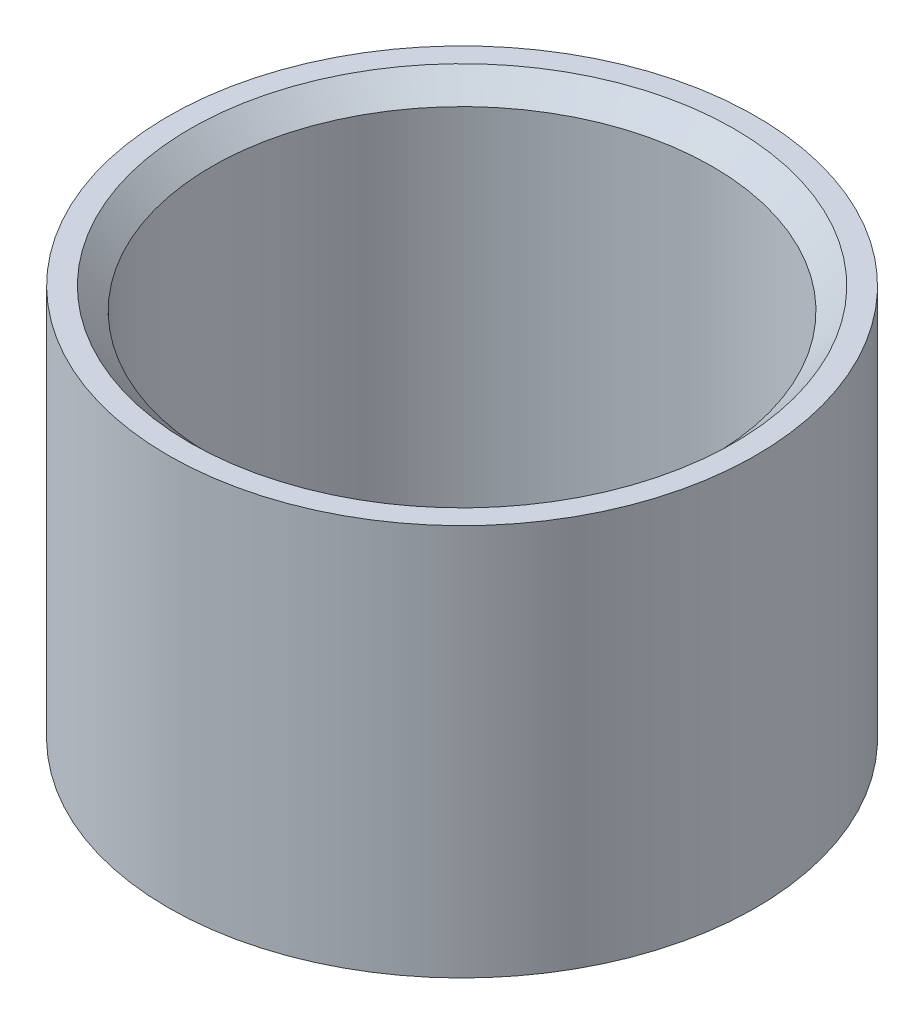
from build123d import *

# Parameters (mm, degrees)
SKETCH1_R           = 1.35
BOSS_EXTRUDE1_DEPTH = 1.8
CUT_EXTRUDE1_REACH  = 3.8
SKETCH2_R           = 1.15
CHAMFER1_SIZE       = 0.1


with BuildPart() as part:
    # Sketch1 → Boss-Extrude1 (new body)
    with BuildSketch(Plane(origin=(0, 0, 0), x_dir=(1, 0, 0), z_dir=(0, 1, 0))):
        Circle(SKETCH1_R)
    extrude(amount=BOSS_EXTRUDE1_DEPTH)

    # Sketch2 → Cut-Extrude1 (cut, up to next)
    with BuildSketch(Plane(origin=(0, 1.8, 0), x_dir=(1, 0, 0), z_dir=(0, 1, 0)), mode=Mode.PRIVATE) as cut_extrude1_sk1:
        Circle(SKETCH2_R)
    cut_extrude1_tool1 = extrude(cut_extrude1_sk1.sketch, amount=-CUT_EXTRUDE1_REACH, mode=Mode.PRIVATE) & part.part
    add(cut_extrude1_tool1.solids().sort_by_distance((0, 1.8, 0))[0], mode=Mode.SUBTRACT)

    # Chamfer1
    chamfer1_edges = [part.edges().sort_by_distance(p)[0] for p in [
        (-1.15, 1.8, 0),
    ]]
    chamfer(chamfer1_edges, length=CHAMFER1_SIZE)


solid = part.part
